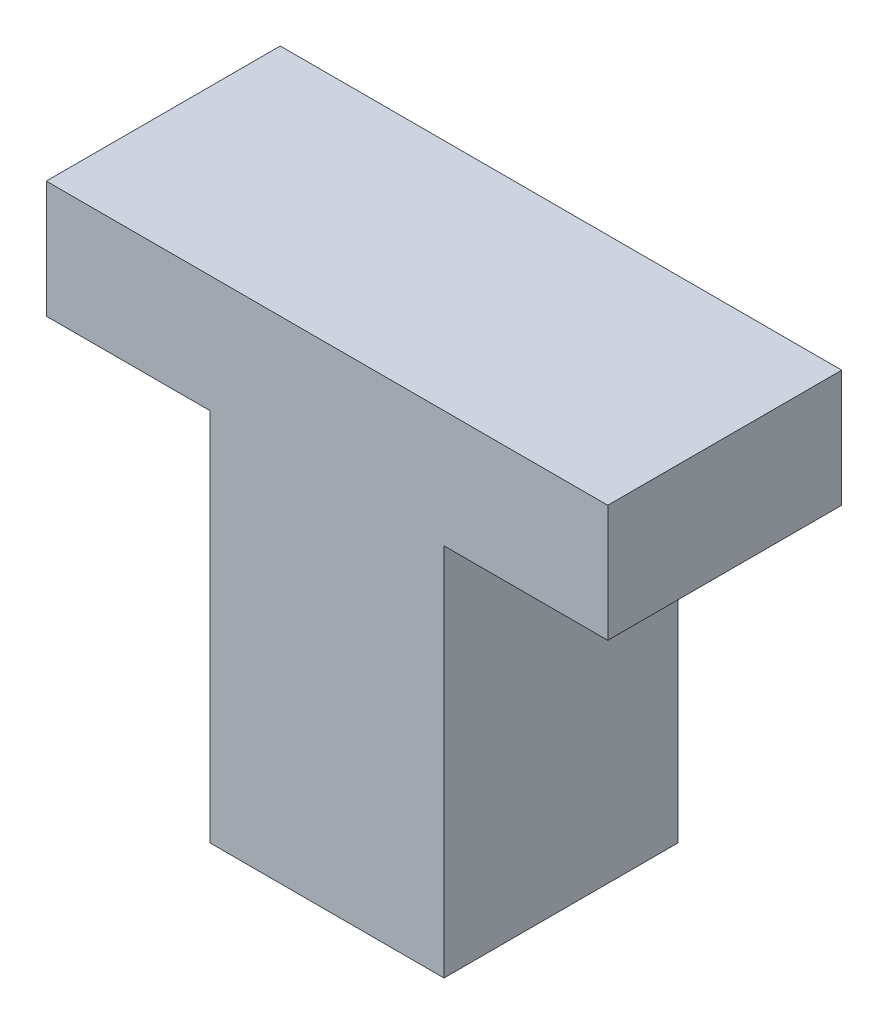
from build123d import *

# Parameters (mm, degrees)
BOSS_EXTRUDE1_DEPTH = 5


with BuildPart() as part:
    # Sketch1 → Boss-Extrude1 (new body)
    with BuildSketch(Plane.XY):
        Polygon((0, 0), (0, 8), (-3.5, 8), (-3.5, 10.5), (8.5, 10.5), (8.5, 8), (5, 8), (5, 0), align=None)
    extrude(amount=BOSS_EXTRUDE1_DEPTH)


solid = part.part
